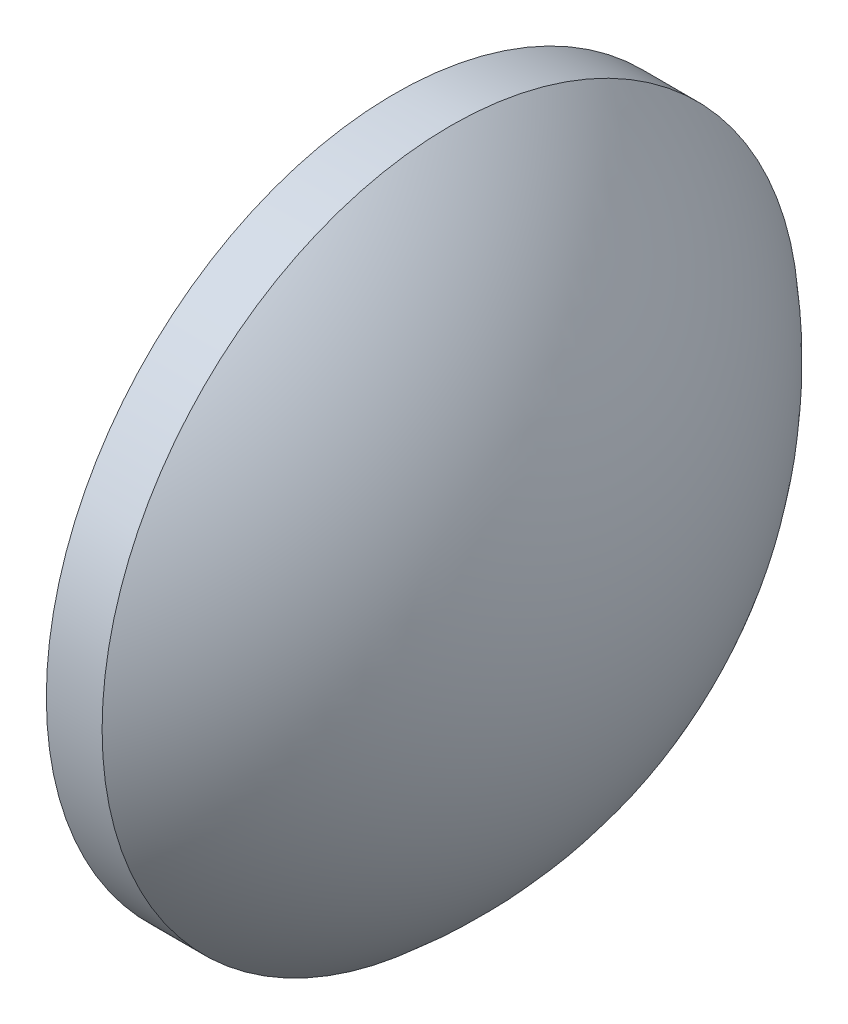
from build123d import *


with BuildPart() as part:
    # 草图1 → 旋转1 (revolve)
    with BuildSketch(Plane.XY):
        with BuildLine():
            Line((541.115150234, 132.598529657), (541.115150234, 145.098529657))
            Line((541.115150234, 145.098529657), (543.115150234, 145.098529657))
            ThreePointArc((543.115150234, 145.098529657), (547.437448897, 139.50123927), (548.975150234, 132.598529657))
            Line((548.975150234, 132.598529657), (541.115150234, 132.598529657))
        make_face()
    revolve(axis=Axis((539.603118993, 132.598529657, 0), (1, 0, 0)))


solid = part.part
